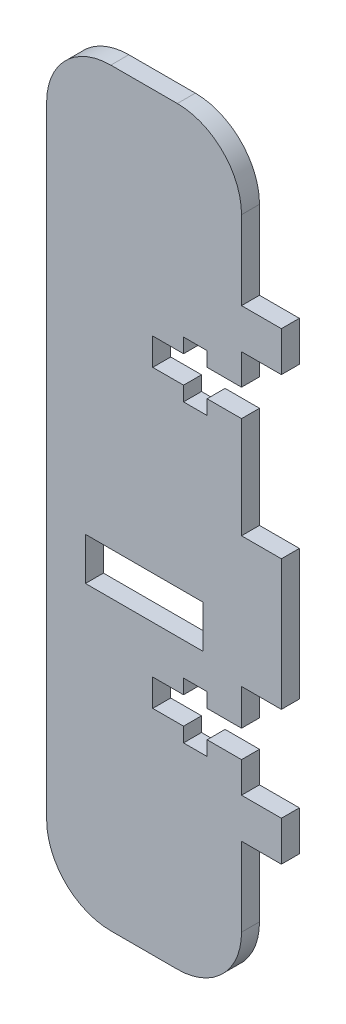
from build123d import *

# Parameters (mm, degrees)
SKETCH3_W           = 18.344
SKETCH3_H           = 6.63149511
BOSS_EXTRUDE2_DEPTH = 2.8


with BuildPart() as part:
    # Sketch3 → Boss-Extrude2 (new body)
    with BuildSketch(Plane.XY):
        with BuildLine():
            Line((55.495440626, -46.5265), (65.850440626, -46.5265))
            ThreePointArc((65.850440626, -46.5265), (72.921508438, -49.455432188), (75.850440626, -56.5265))
            Line((75.850440626, -56.5265), (75.850440626, -68.7965))
            Line((75.850440626, -68.7965), (82.058440626, -68.7965))
            Line((82.058440626, -68.7965), (82.058440626, -75.0055))
            Line((82.058440626, -75.0055), (75.850440626, -75.0055))
            Line((75.850440626, -75.0055), (75.850440626, -79.8025))
            Line((75.850440626, -79.8025), (70.486440626, -79.8025))
            Line((70.486440626, -79.8025), (70.486440626, -77.5455))
            Line((70.486440626, -77.5455), (66.818440626, -77.5455))
            Line((66.818440626, -77.5455), (66.818440626, -79.8025))
            Line((66.818440626, -79.8025), (62.020440626, -79.8025))
            Line((62.020440626, -79.8025), (62.020440626, -84.0365))
            Line((62.020440626, -84.0365), (66.818440626, -84.0365))
            Line((66.818440626, -84.0365), (66.818440626, -86.2935))
            Line((66.818440626, -86.2935), (70.486440626, -86.2935))
            Line((70.486440626, -86.2935), (70.486440626, -84.0365))
            Line((70.486440626, -84.0365), (75.850440626, -84.0365))
            Line((75.850440626, -84.0365), (75.850440626, -99.8395))
            Line((75.850440626, -99.8395), (82.058440626, -99.8395))
            Line((82.058440626, -99.8395), (82.058440626, -120.1605))
            Line((82.058440626, -120.1605), (75.850440626, -120.1605))
            Line((75.850440626, -120.1605), (75.850440626, -125.8055))
            Line((75.850440626, -125.8055), (70.486440626, -125.8055))
            Line((70.486440626, -125.8055), (70.486440626, -123.5475))
            Line((70.486440626, -123.5475), (66.818440626, -123.5475))
            Line((66.818440626, -123.5475), (66.818440626, -125.8055))
            Line((66.818440626, -125.8055), (62.020440626, -125.8055))
            Line((62.020440626, -125.8055), (62.020440626, -130.0385))
            Line((62.020440626, -130.0385), (66.818440626, -130.0385))
            Line((66.818440626, -130.0385), (66.818440626, -132.2955))
            Line((66.818440626, -132.2955), (70.486440626, -132.2955))
            Line((70.486440626, -132.2955), (70.486440626, -130.0385))
            Line((70.486440626, -130.0385), (75.850440626, -130.0385))
            Line((75.850440626, -130.0385), (75.850440626, -134.8365))
            Line((75.850440626, -134.8365), (82.058440626, -134.8365))
            Line((82.058440626, -134.8365), (82.058440626, -141.0445))
            Line((82.058440626, -141.0445), (75.850440626, -141.0445))
            Line((75.850440626, -141.0445), (75.850440626, -153.315747555))
            ThreePointArc((75.850440626, -153.315747555), (72.921508438, -160.386815367), (65.850440626, -163.315747555))
            Line((65.850440626, -163.315747555), (55.495440626, -163.315747555))
            ThreePointArc((55.495440626, -163.315747555), (48.424372815, -160.386815367), (45.495440626, -153.315747555))
            Line((45.495440626, -153.315747555), (45.495440626, -149.654747555))
            Line((45.495440626, -149.654747555), (45.495440626, -56.5265))
            ThreePointArc((45.495440626, -56.5265), (48.424372815, -49.455432188), (55.495440626, -46.5265))
        make_face()
        with Locations((60.71181161, -115.112247555)):
            Rectangle(SKETCH3_W, SKETCH3_H, mode=Mode.SUBTRACT)
    extrude(amount=BOSS_EXTRUDE2_DEPTH)


solid = part.part
